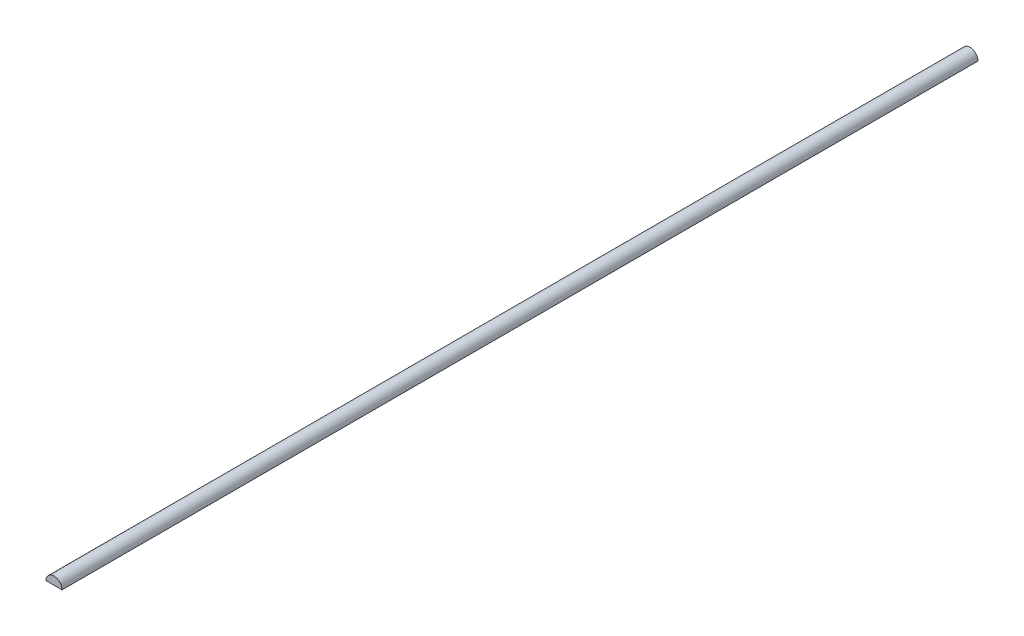
from build123d import *

# Parameters (mm, degrees)
BOSS_EXTRUDE1_DEPTH = 1454.15


with BuildPart() as part:
    # Sketch1 → Boss-Extrude1 (new body)
    with BuildSketch(Plane.XY):
        with BuildLine():
            Line((-12.7, 0), (12.7, 0))
            ThreePointArc((12.7, 0), (0, 12.7), (-12.7, 0))
        make_face()
    extrude(amount=BOSS_EXTRUDE1_DEPTH)


solid = part.part
